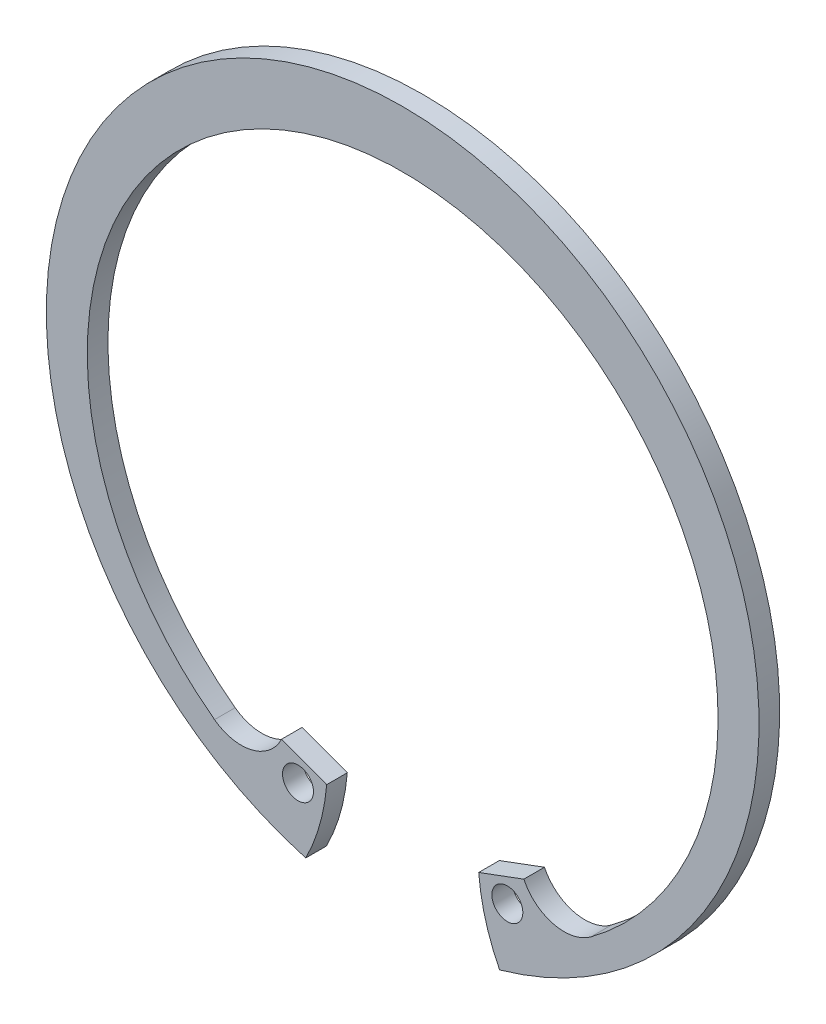
from build123d import *

# Parameters (mm, degrees)
SKETCH3_R                = 1.1811
BOSS_EXTRUDE1_DEPTH      = 0.7874
BOSS_EXTRUDE1_DEPTH_BACK = 0.7874
CUT_EXTRUDE1_DEPTH       = 1.7874


with BuildPart() as part:
    # Sketch3 → Boss-Extrude1 (new body, two sides)
    with BuildSketch(Plane.XY) as boss_extrude1_sk:
        with BuildLine():
            Line((-7.084786794, -26.251475436), (-5.5626, -20.611270532))
            Line((-5.5626, -20.611270532), (-9.244241607, -19.243466133))
            ThreePointArc((-9.244241607, -19.243466133), (-11.503586026, -21.079506525), (-14.357593282, -20.504768227))
            ThreePointArc((-14.357593282, -20.504768227), (0, 22.8727), (14.357593282, -20.504768227))
            ThreePointArc((14.357593282, -20.504768227), (11.503586026, -21.079506525), (9.244241607, -19.243466133))
            Line((9.244241607, -19.243466133), (5.5626, -20.611270532))
            Line((5.5626, -20.611270532), (7.084786794, -26.251475436))
            ThreePointArc((7.084786794, -26.251475436), (0, 27.1907), (-7.084786794, -26.251475436))
        make_face()
        with Locations((-7.986421892, -21.496599331)):
            Circle(SKETCH3_R, mode=Mode.SUBTRACT)
        with Locations((7.986421892, -21.496599331)):
            Circle(SKETCH3_R, mode=Mode.SUBTRACT)
    extrude(amount=BOSS_EXTRUDE1_DEPTH)
    extrude(boss_extrude1_sk.sketch, amount=-BOSS_EXTRUDE1_DEPTH_BACK)

    # Sketch4 → Cut-Extrude1 (cut, symmetric)
    with BuildSketch(Plane.XY):
        with BuildLine():
            Line((-7.395614895, -26.165608092), (-7.395614895, -33.561222987))
            Line((-7.395614895, -33.561222987), (0, -33.561222987))
            Line((0, -33.561222987), (0, -27.1907))
            Line((0, -27.1907), (0, -20.522811972))
            Line((0, -20.522811972), (-5.800698894, -20.522811972))
            ThreePointArc((-5.800698894, -20.522811972), (-6.322313955, -23.422176045), (-7.395614895, -26.165608092))
        make_face()
    cut_extrude1 = extrude(amount=CUT_EXTRUDE1_DEPTH, both=True, mode=Mode.SUBTRACT)

    # Mirror1: Cut-Extrude1 across plane
    add(cut_extrude1.mirror(Plane(origin=(0, 0, 0), x_dir=(0, 0, 1), z_dir=(1, 0, 0))), mode=Mode.SUBTRACT)


solid = part.part
